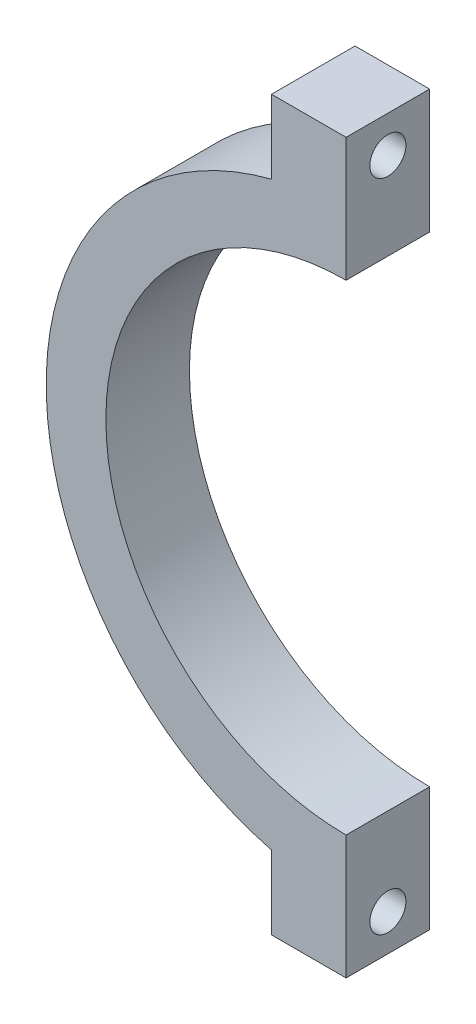
from build123d import *

# Parameters (mm, degrees)
BOSS_EXTRUDE1_DEPTH = 28
SKETCH2_R           = 6.05
CUT_EXTRUDE1_DEPTH  = 28


with BuildPart() as part:
    # Sketch1 → Boss-Extrude1 (new body)
    with BuildSketch(Plane.XY):
        with BuildLine():
            Line((0, -80.5), (0, -122))
            Line((0, -122), (-25, -122))
            Line((-25, -122), (-25, -97.340895825))
            ThreePointArc((-25, -97.340895825), (-100.5, 0), (-25, 97.340895825))
            Line((-25, 97.340895825), (-25, 122))
            Line((-25, 122), (0, 122))
            Line((0, 122), (0, 80.5))
            ThreePointArc((0, 80.5), (-80.5, 0), (0, -80.5))
        make_face()
    extrude(amount=BOSS_EXTRUDE1_DEPTH)

    # Sketch2 → Cut-Extrude1 (cut)
    with BuildSketch(Plane(origin=(0, 0, 0), x_dir=(0, 0, -1), z_dir=(1, 0, 0))):
        with Locations((-14, 109.75)):
            Circle(SKETCH2_R)
        with Locations((-14, -109.75)):
            Circle(SKETCH2_R)
    extrude(amount=-CUT_EXTRUDE1_DEPTH, mode=Mode.SUBTRACT)


solid = part.part
